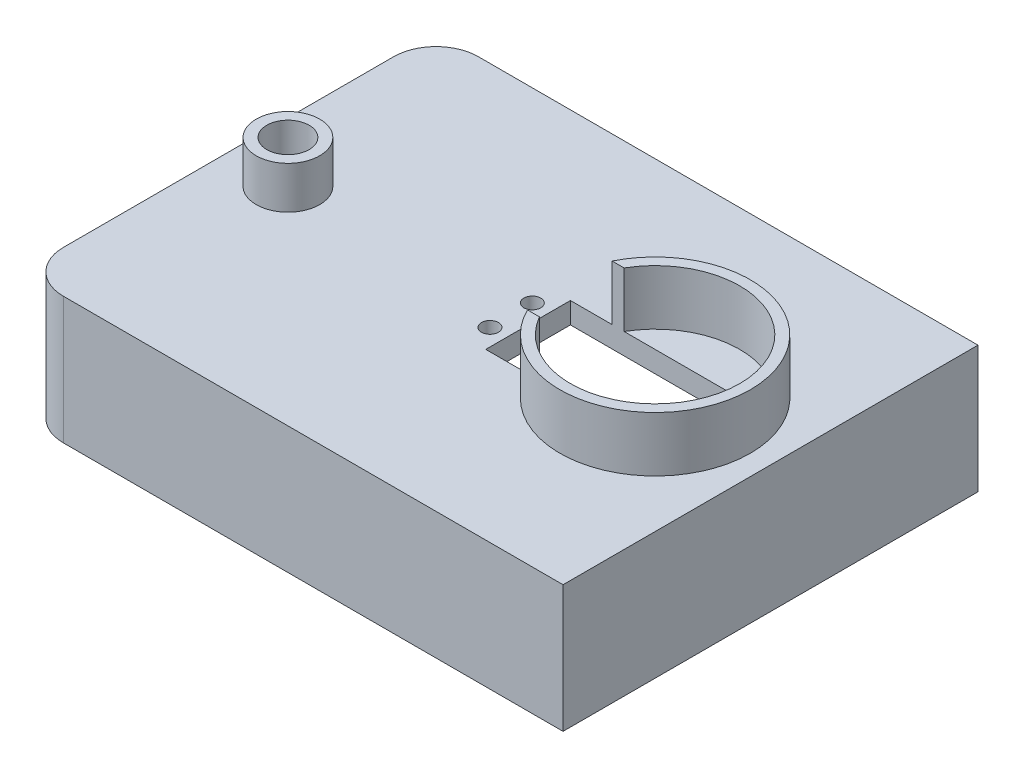
from build123d import *

# Parameters (mm, degrees)
CROQUIS1_W              = 128
CROQUIS1_H              = 98
CROQUIS1_W_2            = 118
CROQUIS1_H_2            = 88
SALIENTE_EXTRUIR5_DEPTH = 30
CROQUIS6_W              = 128
CROQUIS6_H              = 98
SALIENTE_EXTRUIR6_DEPTH = 5
CROQUIS7_W              = 40
CROQUIS7_H              = 20
CORTAR_EXTRUIR2_DEPTH   = 10
REDONDEO1_R             = 10
CROQUIS8_R              = 2
CORTAR_EXTRUIR3_DEPTH   = 10
SALIENTE_EXTRUIR7_DEPTH = 13
CROQUIS11_R             = 5
CORTAR_EXTRUIR4_DEPTH   = 60
CROQUIS12_R             = 7.5
CROQUIS12_R_2           = 5
SALIENTE_EXTRUIR9_DEPTH = 10


with BuildPart() as part:
    # Croquis1 → Saliente-Extruir5 (new body)
    with BuildSketch(Plane(origin=(0, 0, 0), x_dir=(1, 0, 0), z_dir=(0, 1, 0))):
        Rectangle(CROQUIS1_W, CROQUIS1_H)
        Rectangle(CROQUIS1_W_2, CROQUIS1_H_2, mode=Mode.SUBTRACT)
    extrude(amount=SALIENTE_EXTRUIR5_DEPTH)

    # Croquis6 → Saliente-Extruir6 (add)
    with BuildSketch(Plane(origin=(0, 30, 0), x_dir=(1, 0, 0), z_dir=(0, 1, 0))):
        Rectangle(CROQUIS6_W, CROQUIS6_H)
    extrude(amount=-SALIENTE_EXTRUIR6_DEPTH)

    # Croquis7 → Cortar-Extruir2 (cut)
    with BuildSketch(Plane(origin=(0, 30, 0), x_dir=(1, 0, 0), z_dir=(0, 1, 0))):
        with Locations((26.740101048, 0)):
            Rectangle(CROQUIS7_W, CROQUIS7_H)
    extrude(amount=-CORTAR_EXTRUIR2_DEPTH, mode=Mode.SUBTRACT)

    # Redondeo1
    redondeo1_edges = [part.edges().sort_by_distance(p)[0] for p in [
        (-64, 15, 49),
        (-64, 15, -49),
    ]]
    fillet(redondeo1_edges, radius=REDONDEO1_R)

    # Croquis8 → Cortar-Extruir3 (cut)
    with BuildSketch(Plane(origin=(0, 30, 0), x_dir=(1, 0, 0), z_dir=(0, 1, 0))):
        with Locations((50.740101048, -5)):
            Circle(CROQUIS8_R)
        with Locations((50.740101048, 5)):
            Circle(CROQUIS8_R)
        with Locations((2.740101048, 5)):
            Circle(CROQUIS8_R)
        with Locations((2.740101048, -5)):
            Circle(CROQUIS8_R)
    extrude(amount=-CORTAR_EXTRUIR3_DEPTH, mode=Mode.SUBTRACT)

    # Croquis9 → Saliente-Extruir7 (add)
    with BuildSketch(Plane(origin=(0, 30, 0), x_dir=(1, 0, 0), z_dir=(0, 1, 0))):
        with BuildLine():
            Line((16.584456677, 10), (19.419592972, 10))
            ThreePointArc((19.419592972, 10), (56.740101048, 0), (19.419592972, -10))
            Line((19.419592972, -10), (16.584456677, -10))
            ThreePointArc((16.584456677, -10), (59.240101048, 0), (16.584456677, 10))
        make_face()
    extrude(amount=SALIENTE_EXTRUIR7_DEPTH)

    # Croquis11 → Cortar-Extruir4 (cut)
    with BuildSketch(Plane(origin=(0, 30, 0), x_dir=(1, 0, 0), z_dir=(0, 1, 0))):
        with Locations((-49.972168211, 0)):
            Circle(CROQUIS11_R)
    extrude(amount=-CORTAR_EXTRUIR4_DEPTH, mode=Mode.SUBTRACT)

    # Croquis12 → Saliente-Extruir9 (add)
    with BuildSketch(Plane(origin=(0, 30, 0), x_dir=(1, 0, 0), z_dir=(0, 1, 0))):
        with Locations((-49.972168211, 0)):
            Circle(CROQUIS12_R)
        with Locations((-49.972168211, 0)):
            Circle(CROQUIS12_R_2, mode=Mode.SUBTRACT)
    extrude(amount=SALIENTE_EXTRUIR9_DEPTH)


solid = part.part
